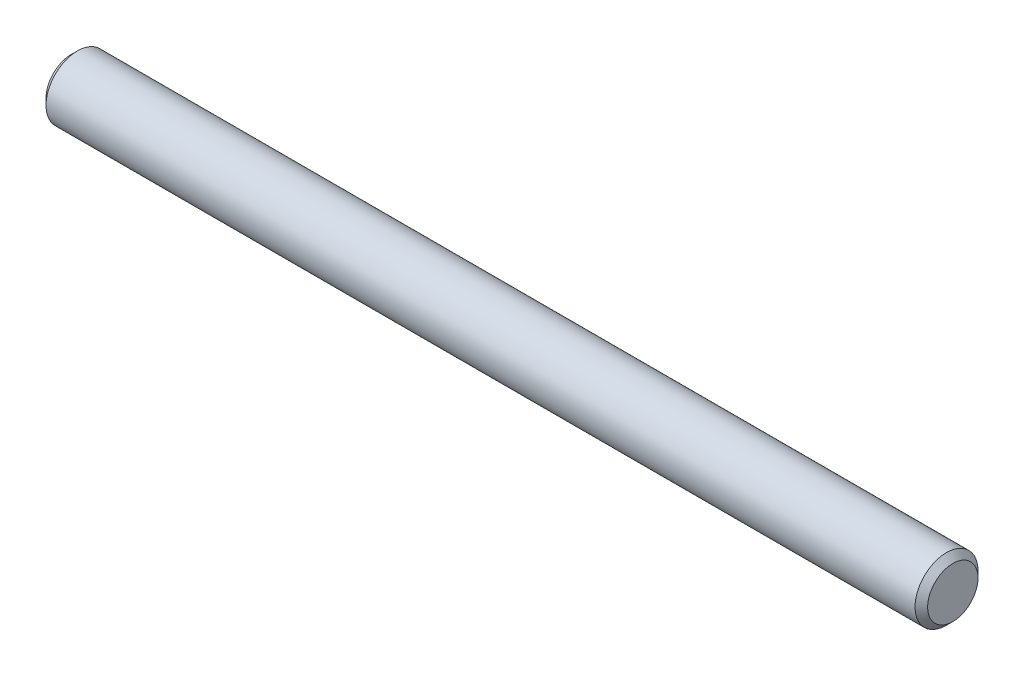
from build123d import *

# Parameters (mm, degrees)
SKETCH2_R           = 0.79375
EXTRUDE1_DEPTH      = 11.1125
EXTRUDE1_DEPTH_BACK = 11.1125
CHAMFER1_SIZE       = 0.15875


with BuildPart() as part:
    # Sketch2 → Extrude1 (new body, two sides)
    with BuildSketch(Plane(origin=(0, 0, 0), x_dir=(0, 0, -1), z_dir=(1, 0, 0))) as extrude1_sk:
        Circle(SKETCH2_R)
    extrude(amount=EXTRUDE1_DEPTH)
    extrude(extrude1_sk.sketch, amount=-EXTRUDE1_DEPTH_BACK)

    # Chamfer1
    chamfer1_edges = [part.edges().sort_by_distance(p)[0] for p in [
        (-11.1125, 0, 0.79375),
        (11.1125, 0, 0.79375),
    ]]
    chamfer(chamfer1_edges, length=CHAMFER1_SIZE)


solid = part.part
